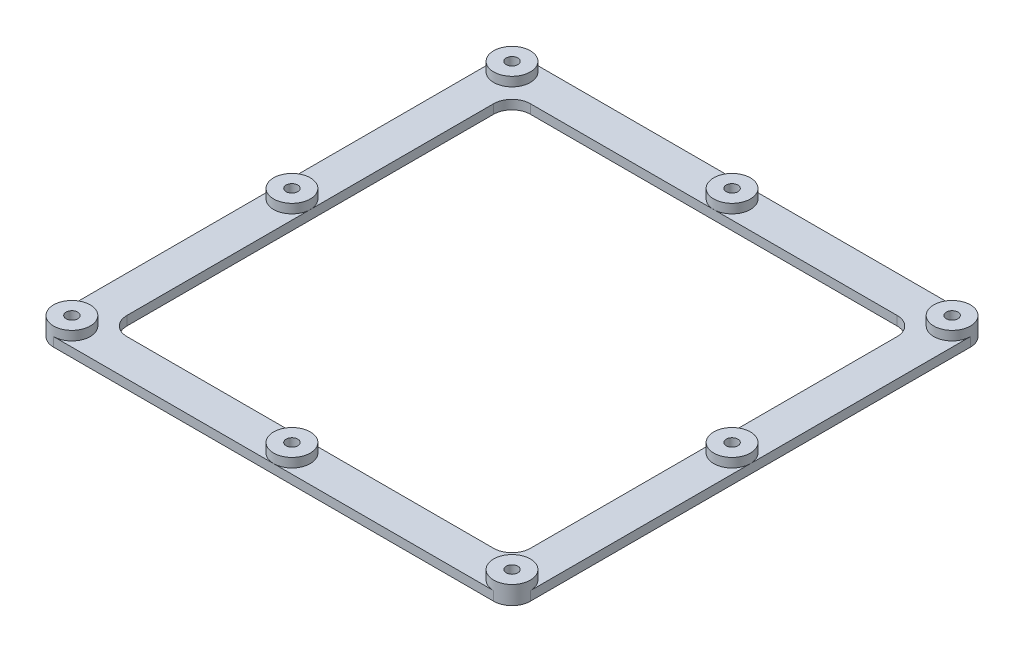
from build123d import *

# Parameters (mm, degrees)
SKETCH1_W              = 165.1
SKETCH1_H              = 165.1
SKETCH1_W_2            = 139.7
SKETCH1_H_2            = 139.7
BOSS_EXTRUDE1_DEPTH    = 6.35
FILLET1_R              = 6.35
F_10_32_TAPPED_HOLE1_D = 4.0386
SKETCH4_OUTSIDE_W      = 213.814
SKETCH4_OUTSIDE_H      = 213.814
SKETCH4_OUTSIDE_R      = 6.35
CUT_EXTRUDE1_DEPTH     = 3.175


with BuildPart() as part:
    # Sketch1 → Boss-Extrude1 (new body)
    with BuildSketch(Plane(origin=(0, 0, 0), x_dir=(1, 0, 0), z_dir=(0, 1, 0))):
        Rectangle(SKETCH1_W, SKETCH1_H)
        Rectangle(SKETCH1_W_2, SKETCH1_H_2, mode=Mode.SUBTRACT)
    extrude(amount=BOSS_EXTRUDE1_DEPTH)

    # Fillet1
    fillet1_edges = [part.edges().sort_by_distance(p)[0] for p in [
        (-69.85, 3.175, -69.85),
        (-69.85, 3.175, 69.85),
        (69.85, 3.175, 69.85),
        (69.85, 3.175, -69.85),
        (-82.55, 3.175, -82.55),
        (82.55, 3.175, -82.55),
        (82.55, 3.175, 82.55),
        (-82.55, 3.175, 82.55),
    ]]
    fillet(fillet1_edges, radius=FILLET1_R)

    # #10-32 Tapped Hole1 (through all)
    with Locations(Plane(origin=(0, 6.35, 0), x_dir=(1, 0, 0), z_dir=(0, 1, 0))):
        with Locations((-76.2, -76.2), (-76.2, 76.2), (76.2, 76.2), (76.2, -76.2), (-76.2, 0), (0, 76.2), (76.2, 0), (0, -76.2)):
            Hole(F_10_32_TAPPED_HOLE1_D / 2)

    # Sketch4 outside → Cut-Extrude1 (cut)
    with BuildSketch(Plane(origin=(0, 6.35, 0), x_dir=(1, 0, 0), z_dir=(0, 1, 0))):
        Rectangle(SKETCH4_OUTSIDE_W, SKETCH4_OUTSIDE_H)
        with Locations(Location((-76.2, 76.2, 0), (0, 0, 90))):
            Circle(SKETCH4_OUTSIDE_R, mode=Mode.SUBTRACT)
        with Locations(Location((-76.2, 0, 0), (0, 0, 270))):
            Circle(SKETCH4_OUTSIDE_R, mode=Mode.SUBTRACT)
        with Locations(Location((-76.2, -76.2, 0), (0, 0, 270))):
            Circle(SKETCH4_OUTSIDE_R, mode=Mode.SUBTRACT)
        with Locations(Location((0, -76.2, 0), (0, 0, 270))):
            Circle(SKETCH4_OUTSIDE_R, mode=Mode.SUBTRACT)
        with Locations(Location((76.2, -76.2, 0), (0, 0, 270))):
            Circle(SKETCH4_OUTSIDE_R, mode=Mode.SUBTRACT)
        with Locations(Location((76.2, 0, 0), (0, 0, 270))):
            Circle(SKETCH4_OUTSIDE_R, mode=Mode.SUBTRACT)
        with Locations(Location((76.2, 76.2, 0), (0, 0, 90))):
            Circle(SKETCH4_OUTSIDE_R, mode=Mode.SUBTRACT)
        with Locations(Location((0, 76.2, 0), (0, 0, 270))):
            Circle(SKETCH4_OUTSIDE_R, mode=Mode.SUBTRACT)
    extrude(amount=-CUT_EXTRUDE1_DEPTH, mode=Mode.SUBTRACT)


solid = part.part
